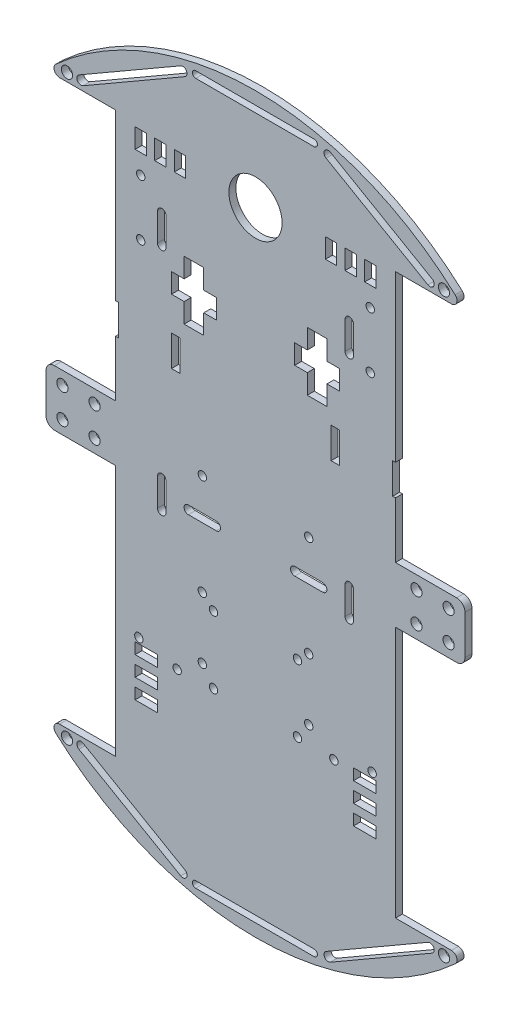
from build123d import *

# Parameters (mm, degrees)
BOSS_EXTRU_1_DEPTH         = 2.5
ESQUISSE2_R                = 9.5
ENL_V_MAT_EXTRU_1_DEPTH    = 229.345077579
ESQUISSE3_W                = 4
ESQUISSE3_H                = 7
ENL_V_MAT_EXTRU_2_DEPTH    = 229.345077579
R_P_TITION_LIN_AIRE1_COUNT = 3
R_P_TITION_LIN_AIRE1_PITCH = 7
ENL_V_MAT_EXTRU_3_DEPTH    = 229.345077579
ESQUISSE5_W                = 3
ESQUISSE5_H                = 11
ENL_V_MAT_EXTRU_4_DEPTH    = 229.345077579
R_P_TITION_LIN_AIRE2_COUNT = 2
R_P_TITION_LIN_AIRE2_PITCH = 22
ESQUISSE6_R                = 1.5
ENL_V_MAT_EXTRU_5_DEPTH    = 229.345077579
ESQUISSE7_W                = 8
ESQUISSE7_H                = 4
ENL_V_MAT_EXTRU_6_DEPTH    = 229.345077579
SYM_TRIE1_COPY_1_SKETCH_W  = 4
SYM_TRIE1_COPY_1_SKETCH_H  = 7
SYM_TRIE1_COPY_1_DEPTH     = 229.345077579
SYM_TRIE1_COPY_2_SKETCH_W  = 4
SYM_TRIE1_COPY_2_SKETCH_H  = 7
SYM_TRIE1_COPY_2_DEPTH     = 229.345077579
SYM_TRIE1_COPY_3_SKETCH_W  = 3
SYM_TRIE1_COPY_3_SKETCH_H  = 11
SYM_TRIE1_COPY_3_DEPTH     = 229.345077579
SKETCH1_R                  = 2
CUT_EXTRUDE1_DEPTH         = 229.345077579
CUT_EXTRUDE3_DEPTH         = 229.345077579
CUT_EXTRUDE3_DEPTH_BACK    = 229.345077579
ESQUISSE1_3_R              = 2
CUT_EXTRUDE4_DEPTH         = 229.345077579


with BuildPart() as part:
    # Esquisse1 → Boss.-Extru.1 (new body)
    with BuildSketch(Plane.XY):
        with BuildLine():
            Line((100, 160.188638056), (119.994239394, 160.188638056))
            ThreePointArc((119.994239394, 160.188638056), (121.860222821, 161.468842356), (121.337366241, 163.670532207))
            ThreePointArc((121.337366241, 163.670532207), (50, 191.188638056), (-21.337366241, 163.670532207))
            ThreePointArc((-21.337366241, 163.670532207), (-21.860222821, 161.468842356), (-19.994239394, 160.188638056))
            Line((-19.994239394, 160.188638056), (0, 160.188638056))
            Line((0, 160.188638056), (0, 70.188638056))
            Line((0, 70.188638056), (-21.828398743, 70.188638056))
            ThreePointArc((-21.828398743, 70.188638056), (-23.949719087, 69.3099584), (-24.828398743, 67.188638056))
            Line((-24.828398743, 67.188638056), (-24.828398743, 53.188638056))
            ThreePointArc((-24.828398743, 53.188638056), (-23.949719087, 51.067317713), (-21.828398743, 50.188638056))
            Line((-21.828398743, 50.188638056), (0, 50.188638056))
            Line((0, 50.188638056), (0, -39.811361944))
            Line((0, -39.811361944), (-19.994239394, -39.811361944))
            ThreePointArc((-19.994239394, -39.811361944), (-21.860222821, -41.091566244), (-21.337366241, -43.293256094))
            ThreePointArc((-21.337366241, -43.293256094), (50, -70.811361944), (121.337366241, -43.293256094))
            ThreePointArc((121.337366241, -43.293256094), (121.860222821, -41.091566244), (119.994239394, -39.811361944))
            Line((119.994239394, -39.811361944), (100, -39.811361944))
            Line((100, -39.811361944), (100, 50.188638056))
            Line((100, 50.188638056), (121.828398743, 50.188638056))
            ThreePointArc((121.828398743, 50.188638056), (123.949719087, 51.067317713), (124.828398743, 53.188638056))
            Line((124.828398743, 53.188638056), (124.828398743, 67.188638056))
            ThreePointArc((124.828398743, 67.188638056), (123.949719087, 69.3099584), (121.828398743, 70.188638056))
            Line((121.828398743, 70.188638056), (100, 70.188638056))
            Line((100, 70.188638056), (100, 160.188638056))
        make_face()
    extrude(amount=BOSS_EXTRU_1_DEPTH)

    # Esquisse2 → Enlèv. mat.-Extru.1 (cut, through all)
    with BuildSketch(Plane(origin=(0, 0, 0), x_dir=(-1, 0, 0), z_dir=(0, 0, -1))):
        with Locations((-50, 155)):
            Circle(ESQUISSE2_R)
        with Locations((-50, -144.622723888)):
            Circle(ESQUISSE2_R)
    extrude(amount=-ENL_V_MAT_EXTRU_1_DEPTH, mode=Mode.SUBTRACT)

    # Esquisse3 → Enlèv. mat.-Extru.2 (cut, through all)
    with BuildSketch(Plane(origin=(0, 0, 0), x_dir=(-1, 0, 0), z_dir=(0, 0, -1))):
        with Locations((-91, 155)):
            Rectangle(ESQUISSE3_W, ESQUISSE3_H)
    enl_v_mat_extru_2 = extrude(amount=-ENL_V_MAT_EXTRU_2_DEPTH, mode=Mode.SUBTRACT)

    # Répétition linéaire1: Enlèv. mat.-Extru.2 ×3
    with Locations(*[(-i * R_P_TITION_LIN_AIRE1_PITCH, 0, 0) for i in range(1, R_P_TITION_LIN_AIRE1_COUNT)]):
        add(enl_v_mat_extru_2, mode=Mode.SUBTRACT)

    # Esquisse4 → Enlèv. mat.-Extru.3 (cut, through all)
    with BuildSketch(Plane(origin=(0, 0, 0), x_dir=(-1, 0, 0), z_dir=(0, 0, -1))):
        Polygon((-75.5, 127.188638056), (-68.5, 127.188638056), (-68.5, 120.188638056), (-64, 120.188638056), (-64, 113.188638056), (-68.5, 113.188638056), (-68.5, 106.188638056), (-75.5, 106.188638056), (-75.5, 113.188638056), (-80, 113.188638056), (-80, 120.188638056), (-75.5, 120.188638056), align=None)
    enl_v_mat_extru_3 = extrude(amount=-ENL_V_MAT_EXTRU_3_DEPTH, mode=Mode.SUBTRACT)

    # Esquisse5 → Enlèv. mat.-Extru.4 (cut, through all)
    with BuildSketch(Plane(origin=(0, 0, 0), x_dir=(-1, 0, 0), z_dir=(0, 0, -1))):
        with Locations((-78.5, 95.688638056)):
            Rectangle(ESQUISSE5_W, ESQUISSE5_H)
    enl_v_mat_extru_4 = extrude(amount=-ENL_V_MAT_EXTRU_4_DEPTH, mode=Mode.SUBTRACT)

    # Répétition linéaire2: Enlèv. mat.-Extru.4 ×2
    with Locations(*[(i * R_P_TITION_LIN_AIRE2_PITCH, 0, 0) for i in range(1, R_P_TITION_LIN_AIRE2_COUNT)]):
        add(enl_v_mat_extru_4, mode=Mode.SUBTRACT)

    # Esquisse6 → Enlèv. mat.-Extru.5 (cut, through all)
    with BuildSketch(Plane(origin=(0, 0, 0), x_dir=(-1, 0, 0), z_dir=(0, 0, -1))):
        with Locations((-91, 144.5)):
            Circle(ESQUISSE6_R)
        with Locations((-91, 124.5)):
            Circle(ESQUISSE6_R)
        with Locations((-65, 22.688638056)):
            Circle(ESQUISSE6_R)
        with Locations((-69, 26.5)):
            Circle(ESQUISSE6_R)
        with Locations((-91.664896814, 1.156313362)):
            Circle(ESQUISSE6_R)
        with Locations((-77.989254532, -1.839818842)):
            Circle(ESQUISSE6_R)
        with Locations((-69, 4.5)):
            Circle(ESQUISSE6_R)
        with Locations((-65, -1.311361944)):
            Circle(ESQUISSE6_R)
        with Locations((-69, 62.5)):
            Circle(ESQUISSE6_R)
        with BuildLine():
            Line((-82, 54.5), (-82, 44.5))
            ThreePointArc((-82, 44.5), (-83.5, 43), (-85, 44.5))
            Line((-85, 44.5), (-85, 54.5))
            ThreePointArc((-85, 54.5), (-83.5, 56), (-82, 54.5))
        make_face()
        with BuildLine():
            Line((-74, 51), (-64, 51))
            ThreePointArc((-64, 51), (-62.5, 49.5), (-64, 48))
            Line((-64, 48), (-74, 48))
            ThreePointArc((-74, 48), (-75.5, 49.5), (-74, 51))
        make_face()
        with BuildLine():
            Line((-82, 136.5), (-82, 126.5))
            ThreePointArc((-82, 126.5), (-83.5, 125), (-85, 126.5))
            Line((-85, 126.5), (-85, 136.5))
            ThreePointArc((-85, 136.5), (-83.5, 138), (-82, 136.5))
        make_face()
        with BuildLine():
            Line((-113.087366241, 164.487676162), (-76.714299282, 185.487676162))
            ThreePointArc((-76.714299282, 185.487676162), (-74.665261177, 184.938638056), (-75.214299282, 182.889599951))
            Line((-75.214299282, 182.889599951), (-111.587366241, 161.889599951))
            ThreePointArc((-111.587366241, 161.889599951), (-113.636404347, 162.438638056), (-113.087366241, 164.487676162))
        make_face()
        with BuildLine():
            Line((-113.087366241, -44.110400049), (-76.714299282, -65.110400049))
            ThreePointArc((-76.714299282, -65.110400049), (-74.665261177, -64.561361944), (-75.214299282, -62.512323838))
            Line((-75.214299282, -62.512323838), (-111.587366241, -41.512323838))
            ThreePointArc((-111.587366241, -41.512323838), (-113.636404347, -42.061361944), (-113.087366241, -44.110400049))
        make_face()
    enl_v_mat_extru_5 = extrude(amount=-ENL_V_MAT_EXTRU_5_DEPTH, mode=Mode.SUBTRACT)

    # Esquisse7 → Enlèv. mat.-Extru.6 (cut, through all)
    with BuildSketch(Plane(origin=(0, 0, 0), x_dir=(-1, 0, 0), z_dir=(0, 0, -1))):
        with Locations((-89, -2.811361944)):
            Rectangle(ESQUISSE7_W, ESQUISSE7_H)
        with Locations((-89, -9.811361944)):
            Rectangle(ESQUISSE7_W, ESQUISSE7_H)
        with Locations((-89, -16.811361944)):
            Rectangle(ESQUISSE7_W, ESQUISSE7_H)
    enl_v_mat_extru_6 = extrude(amount=-ENL_V_MAT_EXTRU_6_DEPTH, mode=Mode.SUBTRACT)

    # Symétrie1: Enlèv. mat.-Extru.2, Enlèv. mat.-Extru.3, Enlèv. mat.-Extru.4, Enlèv. mat.-Extru.5, Enlèv. mat.-Extru.6 across plane
    add(enl_v_mat_extru_2.mirror(Plane(origin=(50, 0, 0), x_dir=(0, 0, 1), z_dir=(1, 0, 0))), mode=Mode.SUBTRACT)
    add(enl_v_mat_extru_3.mirror(Plane(origin=(50, 0, 0), x_dir=(0, 0, 1), z_dir=(1, 0, 0))), mode=Mode.SUBTRACT)
    add(enl_v_mat_extru_4.mirror(Plane(origin=(50, 0, 0), x_dir=(0, 0, 1), z_dir=(1, 0, 0))), mode=Mode.SUBTRACT)
    add(enl_v_mat_extru_5.mirror(Plane(origin=(50, 0, 0), x_dir=(0, 0, 1), z_dir=(1, 0, 0))), mode=Mode.SUBTRACT)
    add(enl_v_mat_extru_6.mirror(Plane(origin=(50, 0, 0), x_dir=(0, 0, 1), z_dir=(1, 0, 0))), mode=Mode.SUBTRACT)

    # Symétrie1 copy 1 sketch → Symétrie1 copy 1 (cut, through all)
    with BuildSketch(Plane(origin=(107, 0, 0), x_dir=(1, 0, 0), z_dir=(0, 0, -1))):
        with Locations((-91, -155)):
            Rectangle(SYM_TRIE1_COPY_1_SKETCH_W, SYM_TRIE1_COPY_1_SKETCH_H)
    extrude(amount=-SYM_TRIE1_COPY_1_DEPTH, mode=Mode.SUBTRACT)

    # Symétrie1 copy 2 sketch → Symétrie1 copy 2 (cut, through all)
    with BuildSketch(Plane(origin=(114, 0, 0), x_dir=(1, 0, 0), z_dir=(0, 0, -1))):
        with Locations((-91, -155)):
            Rectangle(SYM_TRIE1_COPY_2_SKETCH_W, SYM_TRIE1_COPY_2_SKETCH_H)
    extrude(amount=-SYM_TRIE1_COPY_2_DEPTH, mode=Mode.SUBTRACT)

    # Symétrie1 copy 3 sketch → Symétrie1 copy 3 (cut, through all)
    with BuildSketch(Plane(origin=(78, 0, 0), x_dir=(1, 0, 0), z_dir=(0, 0, -1))):
        with Locations((-78.5, -95.688638056)):
            Rectangle(SYM_TRIE1_COPY_3_SKETCH_W, SYM_TRIE1_COPY_3_SKETCH_H)
    extrude(amount=-SYM_TRIE1_COPY_3_DEPTH, mode=Mode.SUBTRACT)

    # Sketch1 → Cut-Extrude1 (cut, through all)
    with BuildSketch(Plane(origin=(0, 0, 0), x_dir=(-1, 0, 0), z_dir=(0, 0, -1))):
        with Locations((17.327503332, 163.188638056)):
            Circle(SKETCH1_R)
        with Locations((-117.327503332, 163.188638056)):
            Circle(SKETCH1_R)
        with Locations((-117.327503332, -42.811361944)):
            Circle(SKETCH1_R)
        with Locations((17.327503332, -42.811361944)):
            Circle(SKETCH1_R)
    extrude(amount=-CUT_EXTRUDE1_DEPTH, mode=Mode.SUBTRACT)

    # Esquisse1_3 → Cut-Extrude3 (cut, two sides: drawn at the far end of the back side and taken through both)
    with BuildSketch(Plane.XY.offset(-CUT_EXTRUDE3_DEPTH_BACK)):
        with Locations((118.979620095, 65.477276112)):
            Circle(ESQUISSE1_3_R)
        with Locations((107.492414614, 54.9)):
            Circle(ESQUISSE1_3_R)
        with Locations((118.979620095, 54.9)):
            Circle(ESQUISSE1_3_R)
        with Locations((107.492414614, 65.477276112)):
            Circle(ESQUISSE1_3_R)
        with Locations((-7.492414614, 54.9)):
            Circle(ESQUISSE1_3_R)
        with Locations((-7.492414614, 65.477276112)):
            Circle(ESQUISSE1_3_R)
        with Locations((-18.979620095, 54.9)):
            Circle(ESQUISSE1_3_R)
        with Locations((-18.979620095, 65.477276112)):
            Circle(ESQUISSE1_3_R)
    extrude(amount=CUT_EXTRUDE3_DEPTH + CUT_EXTRUDE3_DEPTH_BACK, mode=Mode.SUBTRACT)

    # Sketch2 → Cut-Extrude4 (cut, through all)
    with BuildSketch(Plane(origin=(0, 0, 0), x_dir=(-1, 0, 0), z_dir=(0, 0, -1))):
        with BuildLine():
            Line((-70.945354756, 186.647346876), (-28.618983748, 186.647346876))
            ThreePointArc((-28.618983748, 186.647346876), (-27.440942512, 185.46930564), (-28.618983748, 184.291264404))
            Line((-28.618983748, 184.291264404), (-70.945354756, 184.291264404))
            ThreePointArc((-70.945354756, 184.291264404), (-72.123395992, 185.46930564), (-70.945354756, 186.647346876))
        make_face()
        with BuildLine():
            Line((-70.945354756, -66.270070763), (-28.618983748, -66.270070763))
            ThreePointArc((-28.618983748, -66.270070763), (-27.440942512, -65.092029528), (-28.618983748, -63.913988292))
            Line((-28.618983748, -63.913988292), (-70.945354756, -63.913988292))
            ThreePointArc((-70.945354756, -63.913988292), (-72.123395992, -65.092029528), (-70.945354756, -66.270070763))
        make_face()
    extrude(amount=-CUT_EXTRUDE4_DEPTH, mode=Mode.SUBTRACT)


solid = part.part
